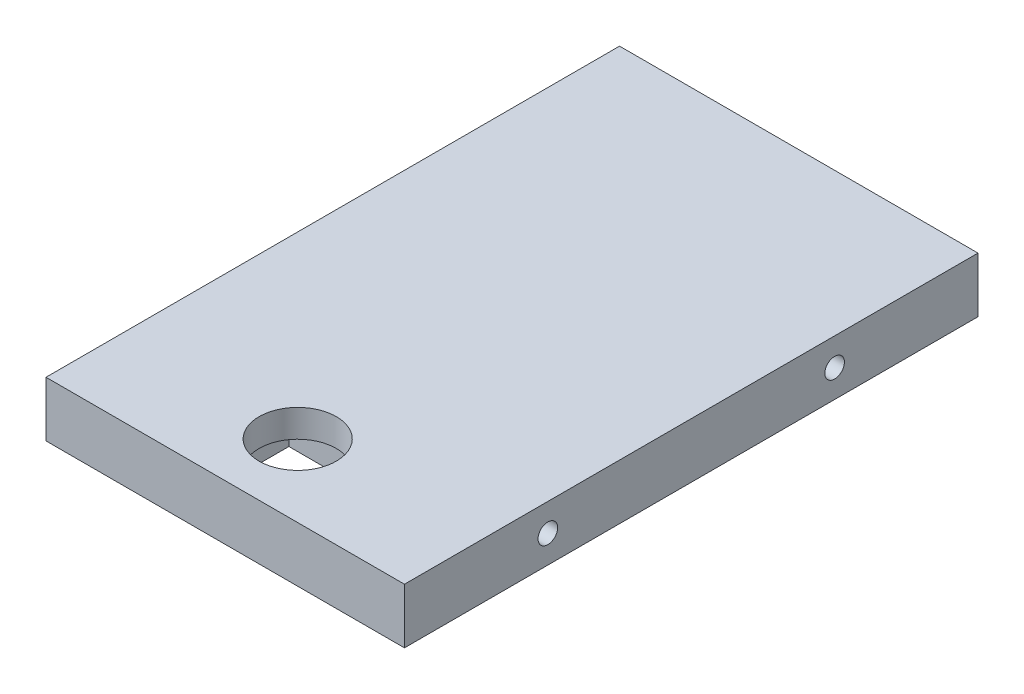
from build123d import *

# Parameters (mm, degrees)
SKETCH1_W                 = 32.5
SKETCH1_H                 = 52
BOSS_EXTRUDE1_DEPTH       = 5
F_2_56_TAPPED_HOLE1_D     = 1.778
F_2_56_TAPPED_HOLE1_DEPTH = 7.46583491
F_2_56_TAPPED_HOLE1_TIP   = 0.53416509
F_2_56_TAPPED_HOLE2_D     = 1.778
F_2_56_TAPPED_HOLE2_DEPTH = 7.46583491
F_2_56_TAPPED_HOLE2_TIP   = 0.53416509
CUT_EXTRUDE2_DEPTH        = 2.5
SKETCH10_R                = 3.5
CUT_EXTRUDE3_DEPTH        = 2.5


with BuildPart() as part:
    # Sketch1 → Boss-Extrude1 (new body)
    with BuildSketch(Plane(origin=(0, 0, 0), x_dir=(1, 0, 0), z_dir=(0, 1, 0))):
        with Locations((16.25, 26)):
            Rectangle(SKETCH1_W, SKETCH1_H)
    extrude(amount=BOSS_EXTRUDE1_DEPTH)

    # #2-56 Tapped Hole1
    with Locations(Plane.ZY):
        with Locations((-39, 2.5), (-13, 2.5)):
            Hole(F_2_56_TAPPED_HOLE1_D / 2, depth=F_2_56_TAPPED_HOLE1_DEPTH)
            with Locations((0, 0, -(F_2_56_TAPPED_HOLE1_DEPTH + F_2_56_TAPPED_HOLE1_TIP / 2))):  # 118° drill point
                Cone(0, F_2_56_TAPPED_HOLE1_D / 2, F_2_56_TAPPED_HOLE1_TIP, mode=Mode.SUBTRACT)

    # #2-56 Tapped Hole2
    with Locations(Plane(origin=(32.5, 0, 0), x_dir=(0, 0, -1), z_dir=(1, 0, 0))):
        with Locations((13, 2.5), (39, 2.5)):
            Hole(F_2_56_TAPPED_HOLE2_D / 2, depth=F_2_56_TAPPED_HOLE2_DEPTH)
            with Locations((0, 0, -(F_2_56_TAPPED_HOLE2_DEPTH + F_2_56_TAPPED_HOLE2_TIP / 2))):  # 118° drill point
                Cone(0, F_2_56_TAPPED_HOLE2_D / 2, F_2_56_TAPPED_HOLE2_TIP, mode=Mode.SUBTRACT)

    # Sketch11 → Cut-Extrude2 (cut)
    with BuildSketch(Plane(origin=(0, 0, 0), x_dir=(-1, 0, 0), z_dir=(0, -1, 0))):
        Polygon((-21.05, 6.57), (-21.05, 10.57), (-11.45, 10.57), (-11.45, 2.57), (-21.05, 2.57), align=None)
    extrude(amount=-CUT_EXTRUDE2_DEPTH, mode=Mode.SUBTRACT)

    # Sketch10 → Cut-Extrude3 (cut)
    with BuildSketch(Plane(origin=(0, 5, 0), x_dir=(1, 0, 0), z_dir=(0, 1, 0))):
        with Locations((16.25, 6.57)):
            Circle(SKETCH10_R)
    extrude(amount=-CUT_EXTRUDE3_DEPTH, mode=Mode.SUBTRACT)


solid = part.part
